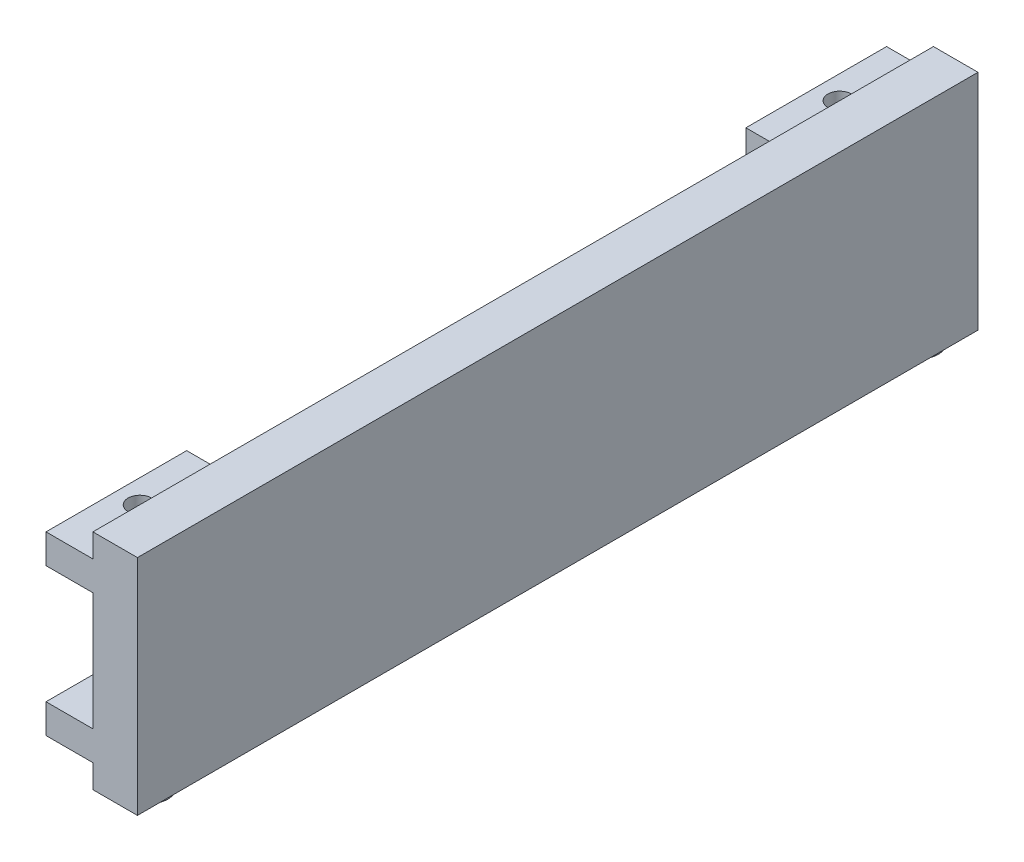
from build123d import *

# Parameters (mm, degrees)
SKETCH1_W           = 38
SKETCH1_H           = 717
BOSS_EXTRUDE1_DEPTH = 190.5
SKETCH3_W           = 120
SKETCH3_H           = 25
BOSS_EXTRUDE2_DEPTH = 40
SKETCH4_R           = 10
CUT_EXTRUDE1_DEPTH  = 506
SKETCH5_R           = 15
BOSS_EXTRUDE3_DEPTH = 5


with BuildPart() as part:
    # Sketch1 → Boss-Extrude1 (new body)
    with BuildSketch(Plane(origin=(0, 0, 0), x_dir=(1, 0, 0), z_dir=(0, 1, 0))):
        with Locations((20.54028436, -361.58056872)):
            Rectangle(SKETCH1_W, SKETCH1_H)
    extrude(amount=BOSS_EXTRUDE1_DEPTH)

    # Sketch3 → Boss-Extrude2 (add)
    with BuildSketch(Plane.ZY.offset(-1.54028436)):
        with Locations((63.08056872, 158)):
            Rectangle(SKETCH3_W, SKETCH3_H)
        with Locations((63.08056872, 32.5)):
            Rectangle(SKETCH3_W, SKETCH3_H)
        with Locations((660.08056872, 32.5)):
            Rectangle(SKETCH3_W, SKETCH3_H)
        with Locations((660.08056872, 158)):
            Rectangle(SKETCH3_W, SKETCH3_H)
    extrude(amount=BOSS_EXTRUDE2_DEPTH)

    # Sketch4 → Cut-Extrude1 (cut)
    with BuildSketch(Plane(origin=(0, 170.5, 0), x_dir=(1, 0, 0), z_dir=(0, 1, 0))):
        with Locations((-18.45971564, -63.08056872)):
            Circle(SKETCH4_R)
        with Locations((-18.45971564, -660.08056872)):
            Circle(SKETCH4_R)
    extrude(amount=-CUT_EXTRUDE1_DEPTH, mode=Mode.SUBTRACT)

    # Sketch5 → Boss-Extrude3 (add)
    with BuildSketch(Plane.XZ):
        with Locations((20.54028436, 690.08056872)):
            Circle(SKETCH5_R)
        with Locations((20.54028436, 33.08056872)):
            Circle(SKETCH5_R)
    extrude(amount=BOSS_EXTRUDE3_DEPTH)


solid = part.part
